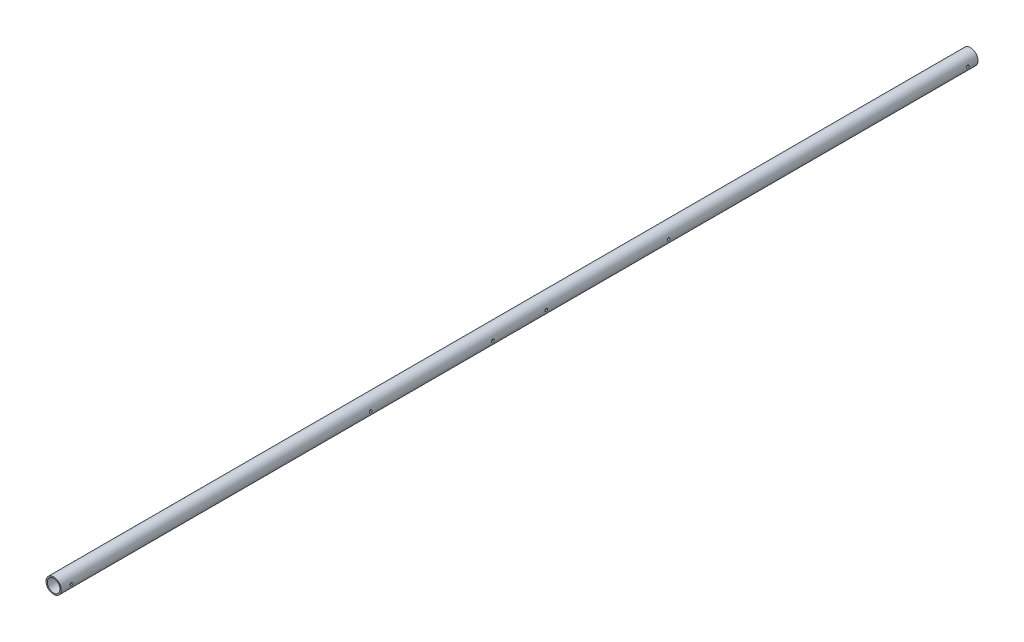
from build123d import *

# Parameters (mm, degrees)
SKETCH1_R               = 19.05
SKETCH1_R_2             = 15.875
BOSS_EXTRUDE1_DEPTH     = 1143
F_1_4_CLEARANCE_HOLE1_D = 6.7564


with BuildPart() as part:
    # Sketch1 → Boss-Extrude1 (new body, symmetric)
    with BuildSketch(Plane.XY):
        Circle(SKETCH1_R)
        Circle(SKETCH1_R_2, mode=Mode.SUBTRACT)
    extrude(amount=BOSS_EXTRUDE1_DEPTH, both=True)

    # 1/4 Clearance Hole1 (through all)
    with Locations(Plane(origin=(19.05, 0, 0), x_dir=(0, 0, -1), z_dir=(1, 0, 0))):
        with Locations((-1117.6, 0), (-66.675, 0), (66.675, 0), (1117.6, 0), (371.475, 0), (-371.475, 0)):
            Hole(F_1_4_CLEARANCE_HOLE1_D / 2)


solid = part.part
